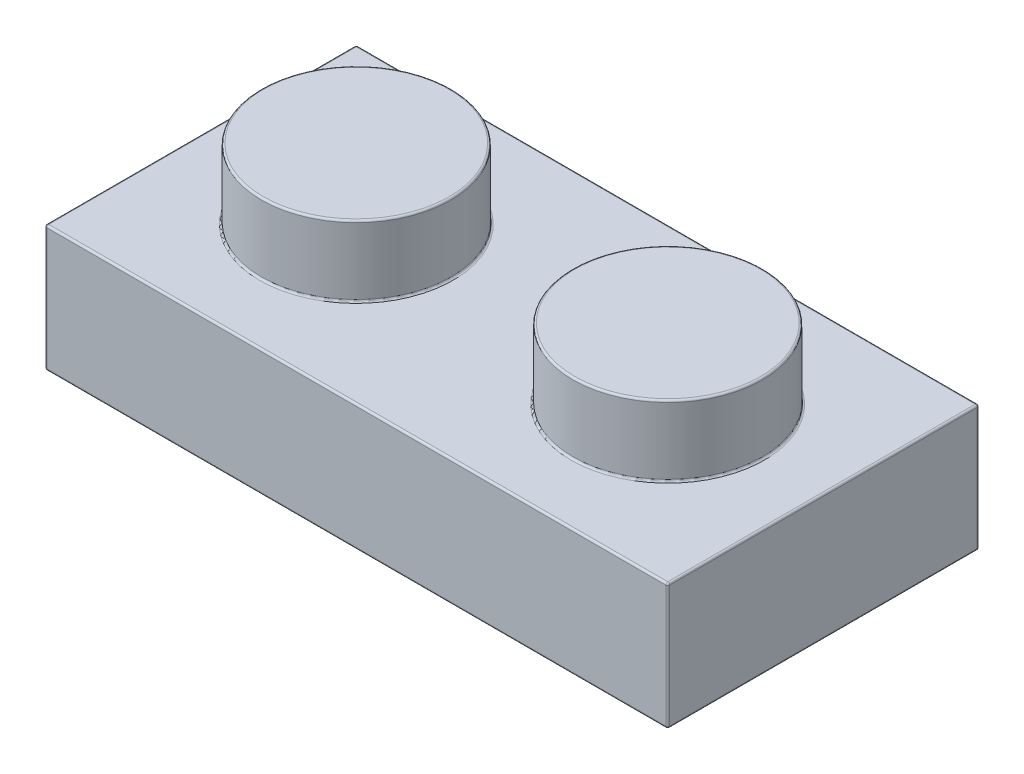
from build123d import *

# Parameters (mm, degrees)
SKETCH1_W       = 7.96
SKETCH1_H       = 7.96
EXTRUDE1_DEPTH  = 3.22
SKETCH2_R       = 2.425
EXTRUDE2_DEPTH  = 1.8
LPATTERN1_COUNT = 2
LPATTERN1_PITCH = 7.96
SHELL1_T        = -1.55
SKETCH4_W       = 12.82
SKETCH4_H       = 4.86
EXTRUDE3_DEPTH  = 0.14
SKETCH5_R       = 1.5
SKETCH5_R_2     = 0.64
EXTRUDE4_DEPTH  = 1.81
FILLET1_R       = 0.05


with BuildPart() as part:
    # Sketch1 → Extrude1 (new body)
    with BuildSketch(Plane(origin=(0, 0, 0), x_dir=(1, 0, 0), z_dir=(0, 1, 0))):
        Rectangle(SKETCH1_W, SKETCH1_H)
    extrude1 = extrude(amount=EXTRUDE1_DEPTH)

    # Sketch2 → Extrude2 (add)
    with BuildSketch(Plane(origin=(0, 3.22, 0), x_dir=(1, 0, 0), z_dir=(0, 1, 0))):
        Circle(SKETCH2_R)
    extrude2 = extrude(amount=EXTRUDE2_DEPTH)

    # LPattern1: Extrude1, Extrude2 ×2
    with Locations(*[(i * LPATTERN1_PITCH, 0, 0) for i in range(1, LPATTERN1_COUNT)]):
        add(extrude1)
        add(extrude2)

    # Shell1
    shell1_openings = [part.faces().sort_by_distance(p)[0] for p in [
        (3.98, 0, 0),
    ]]
    offset(amount=SHELL1_T, openings=shell1_openings, kind=Kind.INTERSECTION)

    # Sketch4 → Extrude3 (cut)
    with BuildSketch(Plane.XZ.offset(-1.67)):
        with Locations((3.98, 0)):
            Rectangle(SKETCH4_W, SKETCH4_H)
    extrude(amount=-EXTRUDE3_DEPTH, mode=Mode.SUBTRACT)

    # Sketch5 → Extrude4 (add)
    with BuildSketch(Plane.XZ.offset(-1.81)):
        with Locations((3.98, 0)):
            Circle(SKETCH5_R)
        with Locations((3.98, 0)):
            Circle(SKETCH5_R_2, mode=Mode.SUBTRACT)
    extrude(amount=EXTRUDE4_DEPTH)

    # Fillet1
    fillet1_edges = [part.edges().sort_by_distance(p)[0] for p in [
        (-3.98, 3.22, 0),
        (3.98, 3.22, 3.98),
        (-2.425, 3.22, 0),
        (-2.425, 5.02, 0),
        (11.94, 0, 0),
        (11.94, 1.61, 3.98),
        (11.94, 1.61, -3.98),
        (11.94, 3.22, 0),
        (5.535, 3.22, 0),
        (5.535, 5.02, 0),
        (3.98, 0, -2.43),
        (10.39, 0.905, -2.43),
        (-2.43, 0, 0),
        (-2.43, 0.905, -2.43),
        (3.98, 0, 2.43),
        (-2.43, 0.905, 2.43),
        (-0.875, 3.47, 0),
        (10.39, 0, 0),
        (10.39, 0.905, 2.43),
        (7.085, 3.47, 0),
        (3.98, 0, 3.98),
        (-0.875, 1.81, 0),
        (7.085, 1.81, 0),
        (3.98, 1.81, 2.43),
        (10.39, 1.81, 0),
        (-3.98, 0, 0),
        (3.98, 1.81, -2.43),
        (-2.43, 1.81, 0),
        (3.98, 0, -3.98),
        (2.48, 1.81, 0),
        (3.34, 1.81, 0),
        (2.48, 0, 0),
        (3.34, 0, 0),
        (3.98, 3.22, -3.98),
        (-3.98, 1.61, 3.98),
        (-3.98, 1.61, -3.98),
    ]]
    fillet(fillet1_edges, radius=FILLET1_R)


solid = part.part
